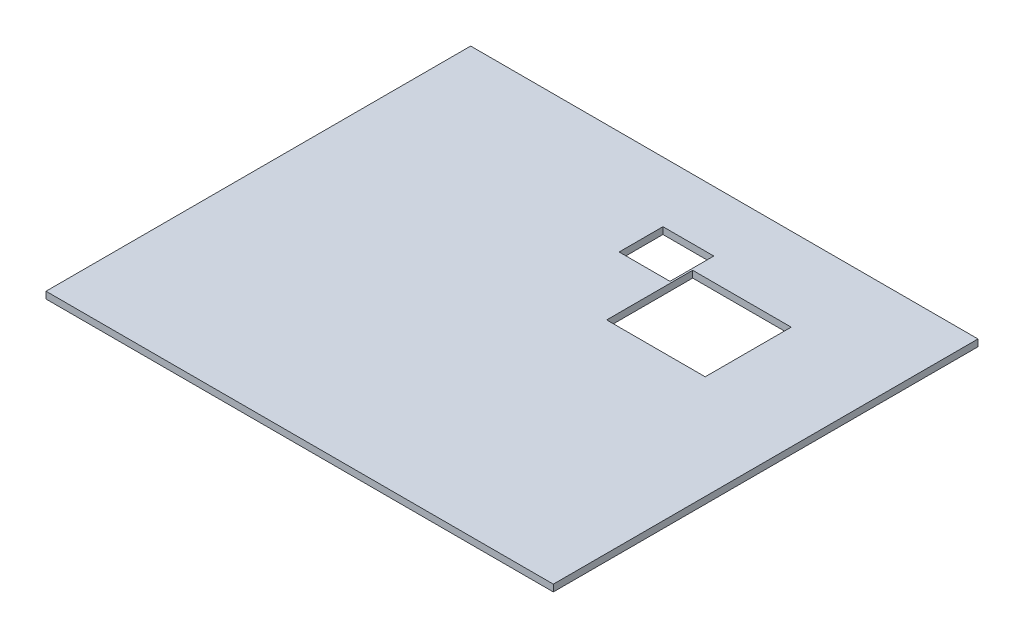
from build123d import *

# Parameters (mm, degrees)
SKETCH1_W           = 89.6
SKETCH1_H           = 75
SKETCH1_W_2         = 17.4
SKETCH1_H_2         = 15.19
SKETCH1_W_3         = 8.98
SKETCH1_H_3         = 7.74
BOSS_EXTRUDE1_DEPTH = 1.2


with BuildPart() as part:
    # Sketch1 → Boss-Extrude1 (new body)
    with BuildSketch(Plane(origin=(0, 0, 0), x_dir=(1, 0, 0), z_dir=(0, 1, 0))):
        Rectangle(SKETCH1_W, SKETCH1_H)
        with Locations((17.8, 15.215)):
            Rectangle(SKETCH1_W_2, SKETCH1_H_2, mode=Mode.SUBTRACT)
        with Locations((4.3, 22.98)):
            Rectangle(SKETCH1_W_3, SKETCH1_H_3, mode=Mode.SUBTRACT)
    extrude(amount=BOSS_EXTRUDE1_DEPTH)


solid = part.part
